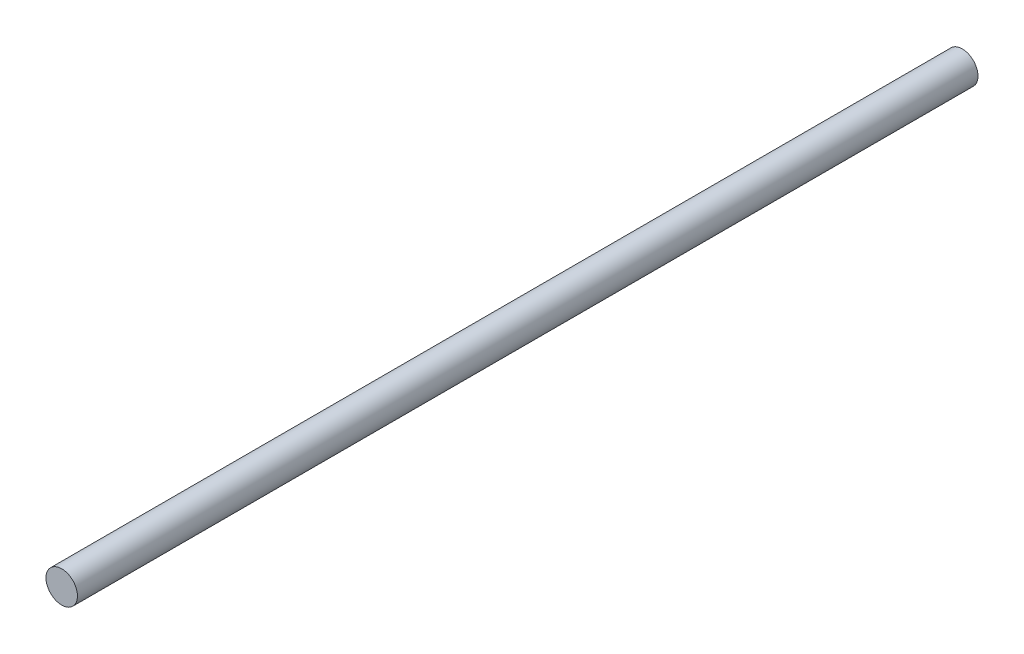
from build123d import *

# Parameters (mm, degrees)
SKETCH1_R           = 5
BOSS_EXTRUDE1_DEPTH = 286


with BuildPart() as part:
    # Sketch1 → Boss-Extrude1 (new body)
    with BuildSketch(Plane.XY):
        Circle(SKETCH1_R)
    extrude(amount=BOSS_EXTRUDE1_DEPTH)


solid = part.part
